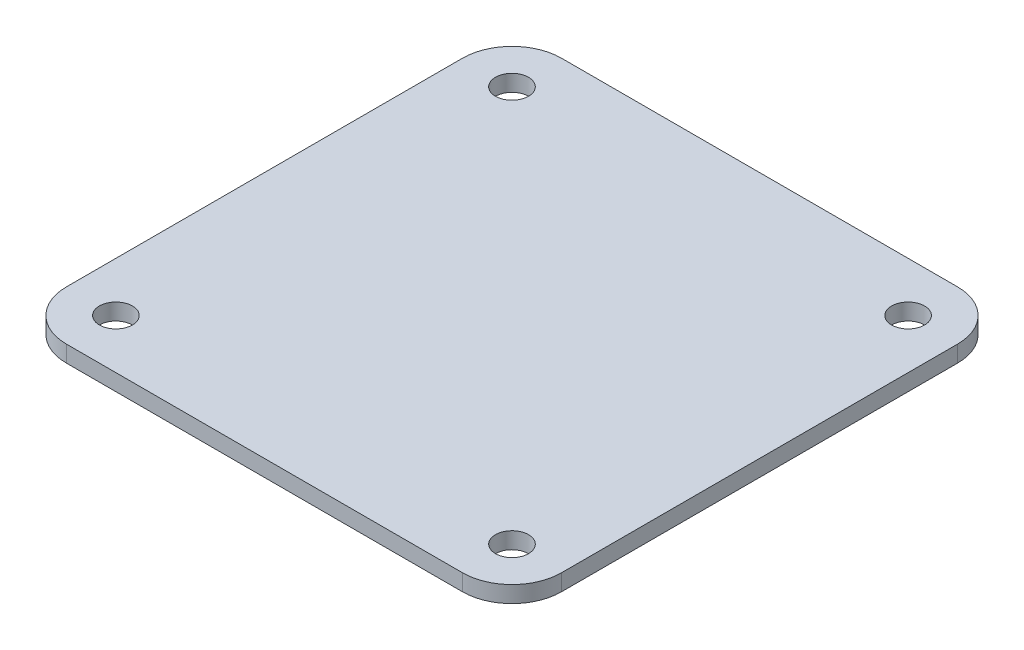
from build123d import *

# Parameters (mm, degrees)
SKETCH1_W           = 47.625
SKETCH1_H           = 47.625
SKETCH1_R           = 1.5875
BOSS_EXTRUDE1_DEPTH = 1.5875
FILLET1_R           = 4.7625


with BuildPart() as part:
    # Sketch1 → Boss-Extrude1 (new body)
    with BuildSketch(Plane(origin=(0, 0, 0), x_dir=(1, 0, 0), z_dir=(0, 1, 0))):
        Rectangle(SKETCH1_W, SKETCH1_H)
        with Locations((-19.05, 19.05)):
            Circle(SKETCH1_R, mode=Mode.SUBTRACT)
        with Locations((19.05, 19.05)):
            Circle(SKETCH1_R, mode=Mode.SUBTRACT)
        with Locations((19.05, -19.05)):
            Circle(SKETCH1_R, mode=Mode.SUBTRACT)
        with Locations((-19.05, -19.05)):
            Circle(SKETCH1_R, mode=Mode.SUBTRACT)
    extrude(amount=BOSS_EXTRUDE1_DEPTH)

    # Fillet1
    fillet1_edges = [part.edges().sort_by_distance(p)[0] for p in [
        (-23.8125, 0.79375, -23.8125),
        (23.8125, 0.79375, -23.8125),
        (23.8125, 0.79375, 23.8125),
        (-23.8125, 0.79375, 23.8125),
    ]]
    fillet(fillet1_edges, radius=FILLET1_R)


solid = part.part
